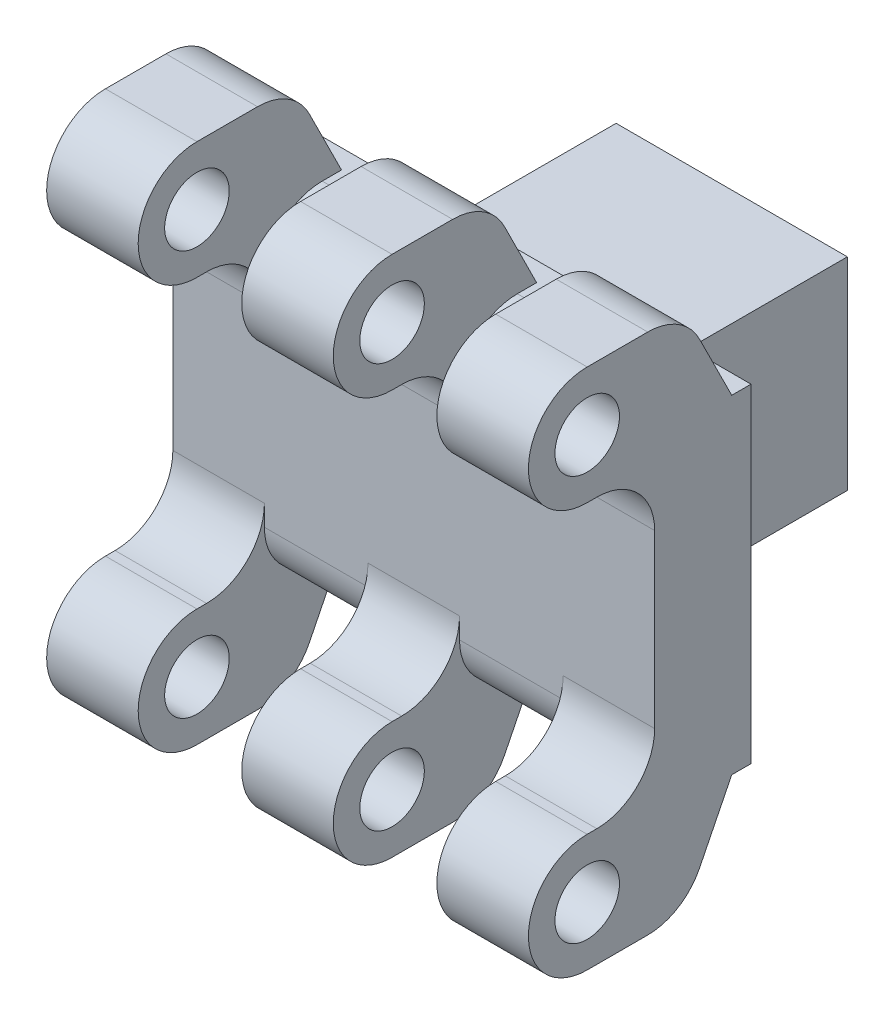
from build123d import *

# Parameters (mm, degrees)
SKETCH1_W               = 50
SKETCH1_H               = 34.11
BOSS_EXTRUDE1_DEPTH     = 10
SKETCH3_W               = 41
SKETCH3_H               = 21
BOSS_EXTRUDE2_DEPTH     = 3
SKETCH2_W               = 3.5
SKETCH2_H               = 31
CUT_EXTRUDE1_DEPTH      = 4
CUT_EXTRUDE1_DEPTH_BACK = 7
SKETCH4_W               = 25
SKETCH4_H               = 21
BOSS_EXTRUDE3_DEPTH     = 20
SKETCH5_R               = 8.35
CUT_EXTRUDE2_DEPTH      = 30
SKETCH6_R               = 3.35
BOSS_EXTRUDE4_DEPTH     = 9.5
LPATTERN1_COUNT         = 3
LPATTERN1_PITCH         = 20.25
MIRROR1_COPY_1_SKETCH_R = 3.35
MIRROR1_COPY_1_DEPTH    = 9.5
MIRROR1_COPY_2_SKETCH_R = 3.35
MIRROR1_COPY_2_DEPTH    = 9.5
FILLET1_R               = 6
SKETCH7_W               = 23
SKETCH7_H               = 21
CUT_EXTRUDE3_DEPTH      = 0.5
FILLET2_R               = 6


with BuildPart() as part:
    # Sketch1 → Boss-Extrude1 (new body)
    with BuildSketch(Plane.XY):
        Rectangle(SKETCH1_W, SKETCH1_H)
    extrude(amount=BOSS_EXTRUDE1_DEPTH)

    # Sketch3 → Boss-Extrude2 (add)
    with BuildSketch(Plane(origin=(0, 0, 0), x_dir=(-1, 0, 0), z_dir=(0, 0, -1))):
        Rectangle(SKETCH3_W, SKETCH3_H)
    extrude(amount=BOSS_EXTRUDE2_DEPTH)

    # Sketch2 → Cut-Extrude1 (cut, two sides)
    with BuildSketch(Plane(origin=(0, 0, 0), x_dir=(-1, 0, 0), z_dir=(0, 0, -1))) as cut_extrude1_sk:
        with Locations((-14.25, 0)):
            Rectangle(SKETCH2_W, SKETCH2_H)
        with Locations((14.25, 0)):
            Rectangle(SKETCH2_W, SKETCH2_H)
    extrude(amount=CUT_EXTRUDE1_DEPTH, mode=Mode.SUBTRACT)
    extrude(cut_extrude1_sk.sketch, amount=-CUT_EXTRUDE1_DEPTH_BACK, mode=Mode.SUBTRACT)

    # Sketch4 → Boss-Extrude3 (add)
    with BuildSketch(Plane(origin=(0, 0, -3), x_dir=(-1, 0, 0), z_dir=(0, 0, -1))):
        Rectangle(SKETCH4_W, SKETCH4_H)
    extrude(amount=BOSS_EXTRUDE3_DEPTH)

    # Sketch5 → Cut-Extrude2 (cut)
    with BuildSketch(Plane(origin=(0, 0, -23), x_dir=(-1, 0, 0), z_dir=(0, 0, -1))):
        Circle(SKETCH5_R)
    extrude(amount=-CUT_EXTRUDE2_DEPTH, mode=Mode.SUBTRACT)

    # Sketch6 → Boss-Extrude4 (add)
    with BuildSketch(Plane(origin=(25, 0, 0), x_dir=(0, 0, -1), z_dir=(1, 0, 0))):
        with BuildLine():
            Line((-17, 27.1), (-7, 27.1))
            Line((-7, 27.1), (-2, 17.055))
            Line((-2, 17.055), (-10, 17.055))
            Line((-10, 17.055), (-10, 14.9))
            Line((-10, 14.9), (-17, 14.9))
            ThreePointArc((-17, 14.9), (-23.1, 21), (-17, 27.1))
        make_face()
        with Locations((-17, 21)):
            Circle(SKETCH6_R, mode=Mode.SUBTRACT)
    boss_extrude4 = extrude(amount=-BOSS_EXTRUDE4_DEPTH)

    # LPattern1: Boss-Extrude4 ×3
    with Locations(*[(-i * LPATTERN1_PITCH, 0, 0) for i in range(1, LPATTERN1_COUNT)]):
        add(boss_extrude4)

    # Mirror1: Boss-Extrude4 across plane
    add(boss_extrude4.mirror(Plane.ZX))

    # Mirror1 copy 1 sketch → Mirror1 copy 1 (add)
    with BuildSketch(Plane(origin=(4.75, 0, 0), x_dir=(0, 0, -1), z_dir=(1, 0, 0))):
        with BuildLine():
            Line((-17, -27.1), (-7, -27.1))
            Line((-7, -27.1), (-2, -17.055))
            Line((-2, -17.055), (-10, -17.055))
            Line((-10, -17.055), (-10, -14.9))
            Line((-10, -14.9), (-17, -14.9))
            ThreePointArc((-17, -14.9), (-23.1, -21), (-17, -27.1))
        make_face()
        with Locations((-17, -21)):
            Circle(MIRROR1_COPY_1_SKETCH_R, mode=Mode.SUBTRACT)
    extrude(amount=-MIRROR1_COPY_1_DEPTH)

    # Mirror1 copy 2 sketch → Mirror1 copy 2 (add)
    with BuildSketch(Plane(origin=(-15.5, 0, 0), x_dir=(0, 0, -1), z_dir=(1, 0, 0))):
        with BuildLine():
            Line((-17, -27.1), (-7, -27.1))
            Line((-7, -27.1), (-2, -17.055))
            Line((-2, -17.055), (-10, -17.055))
            Line((-10, -17.055), (-10, -14.9))
            Line((-10, -14.9), (-17, -14.9))
            ThreePointArc((-17, -14.9), (-23.1, -21), (-17, -27.1))
        make_face()
        with Locations((-17, -21)):
            Circle(MIRROR1_COPY_2_SKETCH_R, mode=Mode.SUBTRACT)
    extrude(amount=-MIRROR1_COPY_2_DEPTH)

    # Fillet1
    fillet1_edges = [part.edges().sort_by_distance(p)[0] for p in [
        (20.25, 27.1, 7),
        (20.25, 14.9, 10),
        (0, 27.1, 7),
        (0, 14.9, 10),
        (-20.25, 27.1, 7),
        (-20.25, 14.9, 10),
        (20.25, -14.9, 10),
        (20.25, -27.1, 7),
        (0, -14.9, 10),
        (0, -27.1, 7),
        (-20.25, -14.9, 10),
        (-20.25, -27.1, 7),
    ]]
    fillet(fillet1_edges, radius=FILLET1_R)

    # Sketch7 → Cut-Extrude3 (cut)
    with BuildSketch(Plane(origin=(12.5, 0, 0), x_dir=(0, 0, -1), z_dir=(1, 0, 0))):
        with Locations((11.5, 0)):
            Rectangle(SKETCH7_W, SKETCH7_H)
    cut_extrude3 = extrude(amount=-CUT_EXTRUDE3_DEPTH, mode=Mode.SUBTRACT)

    # Mirror2: Cut-Extrude3 across plane
    add(cut_extrude3.mirror(Plane(origin=(0, 0, 0), x_dir=(0, 0, 1), z_dir=(1, 0, 0))), mode=Mode.SUBTRACT)

    # Fillet2
    fillet2_edges = [part.edges().sort_by_distance(p)[0] for p in [
        (10.125, 17.055, 10),
        (-10.125, 17.055, 10),
        (10.125, -17.055, 10),
        (-10.125, -17.055, 10),
    ]]
    fillet(fillet2_edges, radius=FILLET2_R)


solid = part.part
